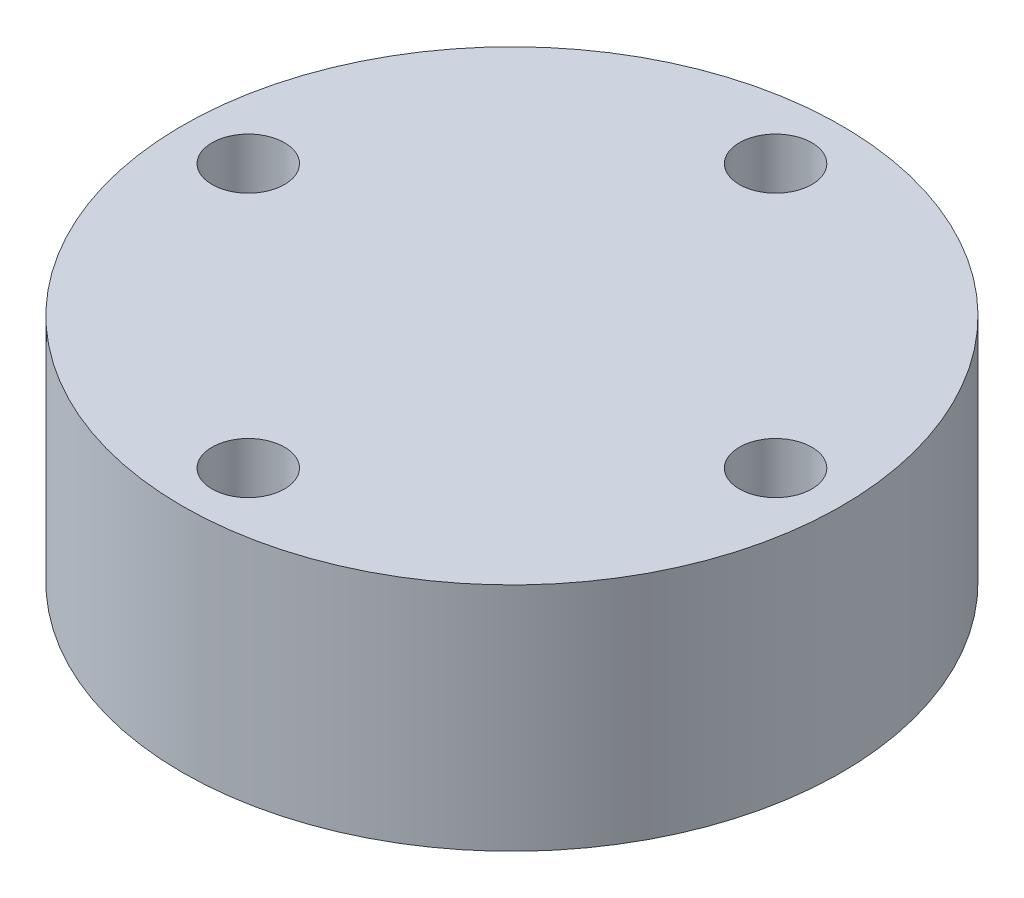
from build123d import *

# Parameters (mm, degrees)
SKETCH1_R           = 10
SKETCH1_R_2         = 1.1
BOSS_EXTRUDE1_DEPTH = 7


with BuildPart() as part:
    # Sketch1 → Boss-Extrude1 (new body)
    with BuildSketch(Plane(origin=(0, 0, 0), x_dir=(1, 0, 0), z_dir=(0, 1, 0))):
        Circle(SKETCH1_R)
        with Locations((0, 8)):
            Circle(SKETCH1_R_2, mode=Mode.SUBTRACT)
        with Locations((8, 0)):
            Circle(SKETCH1_R_2, mode=Mode.SUBTRACT)
        with Locations((0, -8)):
            Circle(SKETCH1_R_2, mode=Mode.SUBTRACT)
        with Locations((-8, 0)):
            Circle(SKETCH1_R_2, mode=Mode.SUBTRACT)
    extrude(amount=BOSS_EXTRUDE1_DEPTH)


solid = part.part
